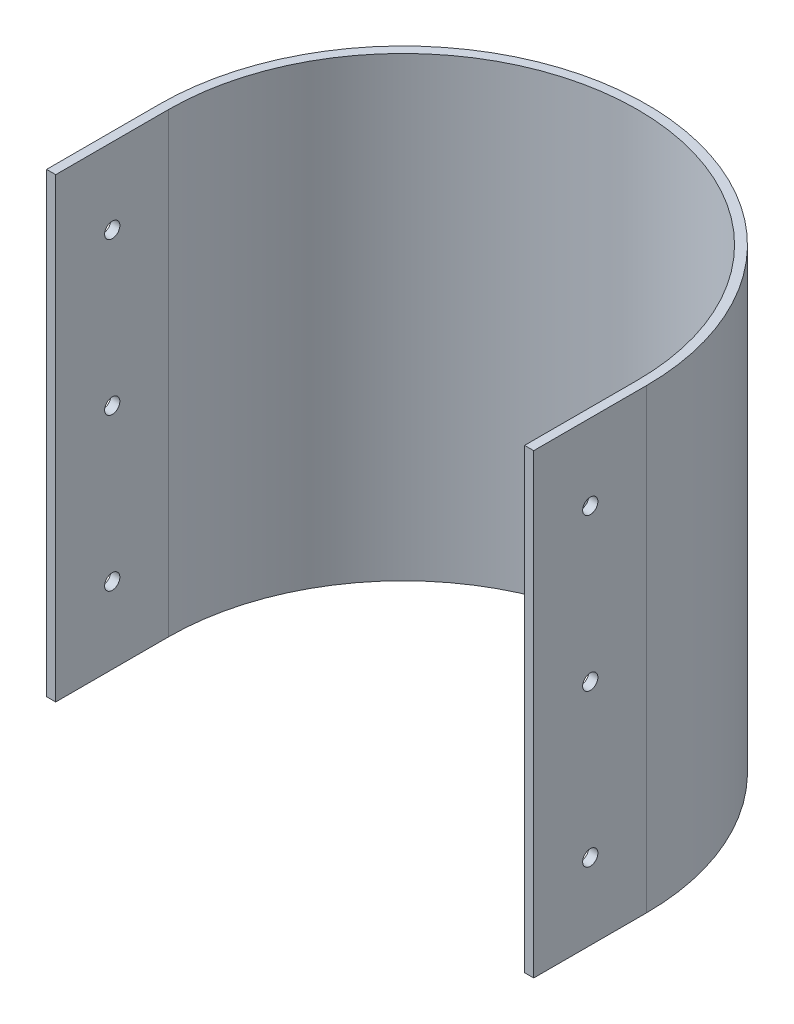
from build123d import *

# Parameters (mm, degrees)
BOSS_EXTRUDE1_DEPTH = 150
SKETCH2_R           = 2.5
CUT_EXTRUDE1_DEPTH  = 161


with BuildPart() as part:
    # Sketch1 → Boss-Extrude1 (new body)
    with BuildSketch(Plane(origin=(0, 0, 0), x_dir=(1, 0, 0), z_dir=(0, 1, 0))):
        with BuildLine():
            Line((-80.885057471, 0), (-80.885057471, -37.067376772))
            Line((-80.885057471, -37.067376772), (-77.885057471, -37.067376772))
            Line((-77.885057471, -37.067376772), (-77.885057471, 0))
            ThreePointArc((-77.885057471, 0), (-0.885057471, 77), (76.114942529, 0))
            Line((76.114942529, 0), (76.114942529, -37.067376772))
            Line((76.114942529, -37.067376772), (79.114942529, -37.067376772))
            Line((79.114942529, -37.067376772), (79.114942529, 0))
            ThreePointArc((79.114942529, 0), (-0.885057471, 80), (-80.885057471, 0))
        make_face()
    extrude(amount=BOSS_EXTRUDE1_DEPTH)

    # Sketch2 → Cut-Extrude1 (cut, through all)
    with BuildSketch(Plane(origin=(79.114942529, 0, 0), x_dir=(0, 0, -1), z_dir=(1, 0, 0))):
        with Locations((-18.5, 125)):
            Circle(SKETCH2_R)
        with Locations((-18.5, 75)):
            Circle(SKETCH2_R)
        with Locations((-18.5, 25)):
            Circle(SKETCH2_R)
    extrude(amount=-CUT_EXTRUDE1_DEPTH, mode=Mode.SUBTRACT)


solid = part.part
